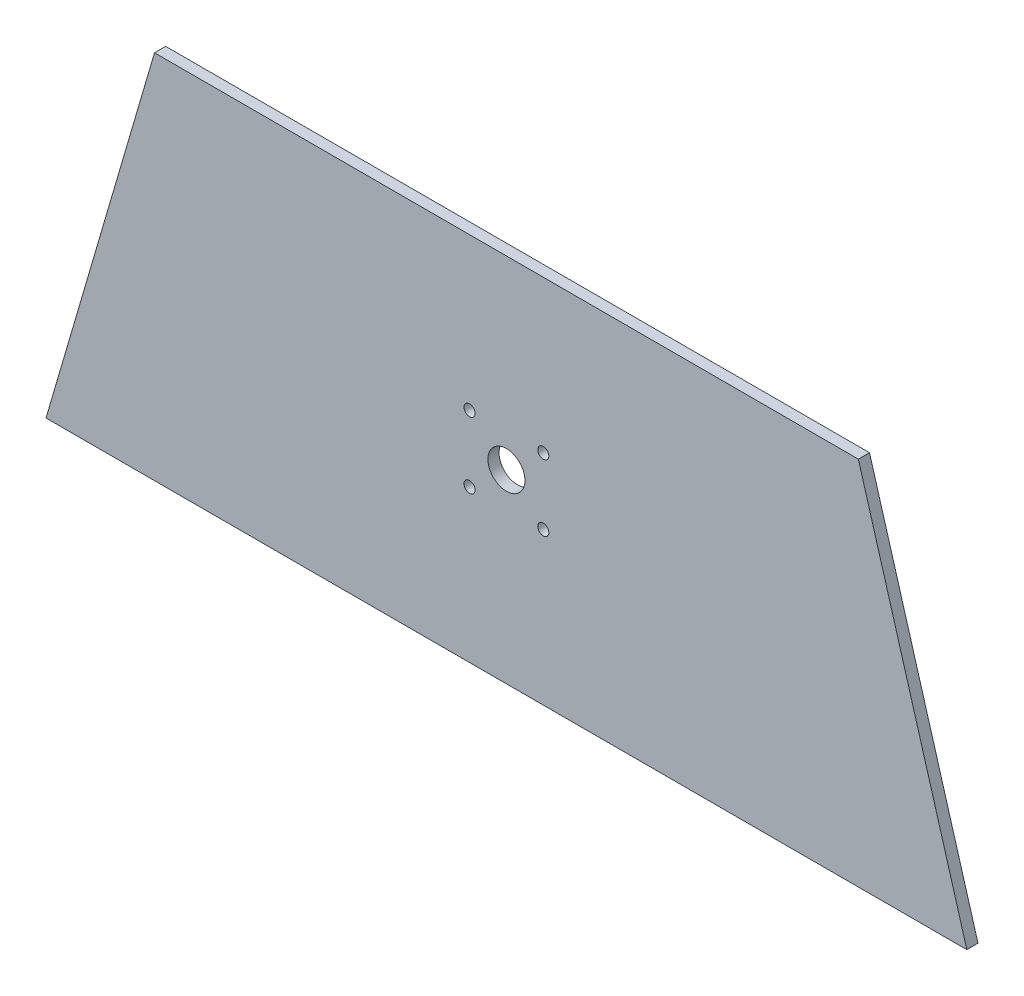
from build123d import *

# Parameters (mm, degrees)
BOSS_EXTRUDE1_DEPTH        = 3
BOSS_EXTRUDE1_DEPTH_BACK   = 0.006725904
F_10_0MM_DOWEL_HOLE1_D     = 10
F_10_0MM_DOWEL_HOLE1_DEPTH = 3.006725904
F_3_0MM_DOWEL_HOLE1_D      = 3
F_3_0MM_DOWEL_HOLE1_DEPTH  = 3.006725904


with BuildPart() as part:
    # Sketch1 → Boss-Extrude1 (new body, two sides)
    with BuildSketch(Plane.XY) as boss_extrude1_sk:
        Polygon((-3.5, 0), (245, 0), (215.720058283, 100), (25.779941717, 100), align=None)
    extrude(amount=BOSS_EXTRUDE1_DEPTH)
    extrude(boss_extrude1_sk.sketch, amount=-BOSS_EXTRUDE1_DEPTH_BACK)

    # Ø10.0mm Dowel Hole1
    with Locations(Plane.XY.offset(3)):
        with Locations((120.75, 50)):
            Hole(F_10_0MM_DOWEL_HOLE1_D / 2, depth=F_10_0MM_DOWEL_HOLE1_DEPTH)

    # Ø3.0mm Dowel Hole1
    with Locations(Plane.XY.offset(3)):
        with Locations((110.8, 58.95), (130.7, 58.95), (130.7, 41.05), (110.8, 41.05)):
            Hole(F_3_0MM_DOWEL_HOLE1_D / 2, depth=F_3_0MM_DOWEL_HOLE1_DEPTH)


solid = part.part
